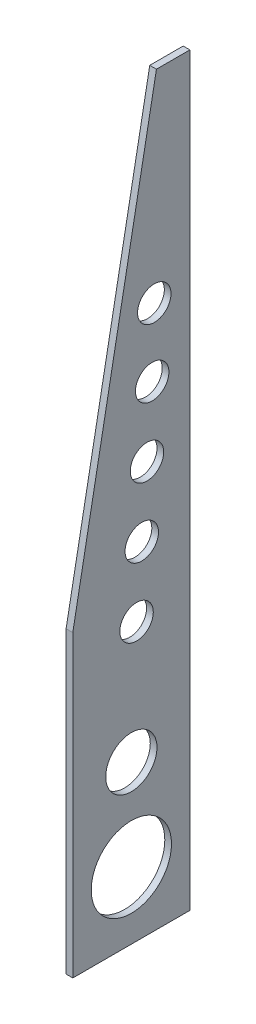
from build123d import *

# Parameters (mm, degrees)
SKETCH1_R           = 9.7234375
SKETCH1_R_2         = 15.24
SKETCH1_R_3         = 6.35
BOSS_EXTRUDE1_DEPTH = 2.54


with BuildPart() as part:
    # Sketch1 → Boss-Extrude1 (new body)
    with BuildSketch(Plane(origin=(0, 0, 0), x_dir=(0, 0, -1), z_dir=(1, 0, 0))):
        Polygon((199.119533938, 358.909346267), (167.369533938, 189.576012933), (167.369533938, 76.016846267), (211.819533938, 76.016846267), (211.819533938, 308.109346267), (211.819533938, 358.909346267), align=None)
        with Locations((189.594533938, 135.865596267)):
            Circle(SKETCH1_R, mode=Mode.SUBTRACT)
        with Locations((189.594533938, 101.416846267)):
            Circle(SKETCH1_R_2, mode=Mode.SUBTRACT)
        with Locations((191.572880687, 181.032184657)):
            Circle(SKETCH1_R_3, mode=Mode.SUBTRACT)
        with Locations((193.551227437, 206.355023047)):
            Circle(SKETCH1_R_3, mode=Mode.SUBTRACT)
        with Locations((195.529574186, 231.677861438)):
            Circle(SKETCH1_R_3, mode=Mode.SUBTRACT)
        with Locations((197.507920935, 257.000699828)):
            Circle(SKETCH1_R_3, mode=Mode.SUBTRACT)
        with Locations((198.308463246, 282.388081182)):
            Circle(SKETCH1_R_3, mode=Mode.SUBTRACT)
    extrude(amount=BOSS_EXTRUDE1_DEPTH)


solid = part.part
